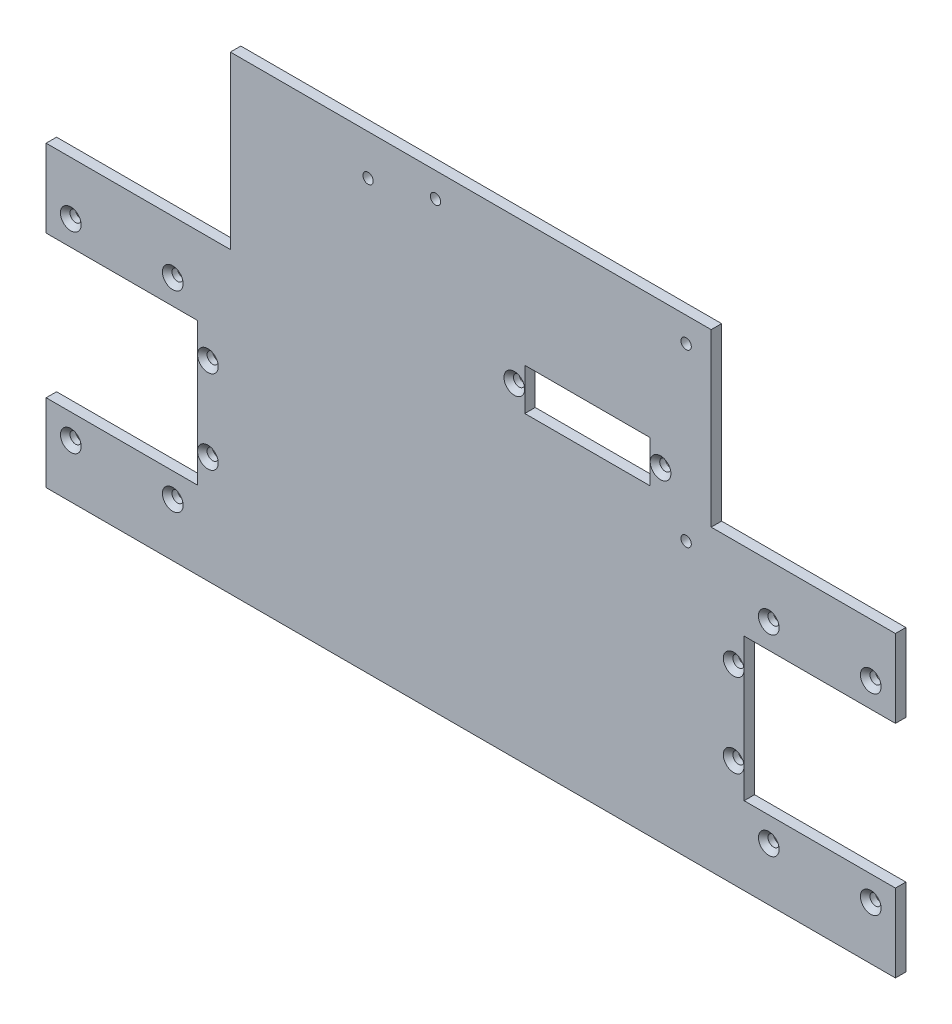
from build123d import *

# Parameters (mm, degrees)
PROFILE_EXTRUDE_DEPTH                           = 3.175
CSK_FOR_M3_FLAT_HEAD_MACHINE_SCREW1_D           = 3.4
CSK_FOR_M3_FLAT_HEAD_MACHINE_SCREW1_CSINK_D     = 6.3
CSK_FOR_M3_FLAT_HEAD_MACHINE_SCREW1_CSINK_ANGLE = 90
FILM_FEEDER_CLEARANCE_SKETCH_W                  = 46
FILM_FEEDER_CLEARANCE_SKETCH_H                  = 43.35
FILM_FEEDER_CLEARANCE_CUT_DEPTH                 = 4.175
GANTRY_MOUNTING_HOLE_SKETCH_R                   = 1.575
GANTRY_MOUNTING_HOLE_CUT_DEPTH                  = 4.175
ERASER_MOUNTING_HOLE_SKETCH_R                   = 1.575
ERASER_MOUNTING_HOLE_CUT_DEPTH                  = 4.175
FILM_FRICTION_GUIDE_MOUNTING_HOLES_D            = 3.4
FILM_FRICTION_GUIDE_MOUNTING_HOLES_CSINK_D      = 6.3
FILM_FRICTION_GUIDE_MOUNTING_HOLES_CSINK_ANGLE  = 90
BELT_PASSAGEWAY_SKETCH_W                        = 38.1
BELT_PASSAGEWAY_SKETCH_H                        = 12.7
BELT_PASSAGEWAY_CUT_DEPTH                       = 4.175
CSK_FOR_M3_FLAT_HEAD_MACHINE_SCREW3_D           = 3.4
CSK_FOR_M3_FLAT_HEAD_MACHINE_SCREW3_CSINK_D     = 6.3
CSK_FOR_M3_FLAT_HEAD_MACHINE_SCREW3_CSINK_ANGLE = 90


with BuildPart() as part:
    # Profile Sketch → Profile Extrude (new body)
    with BuildSketch(Plane.XY):
        Polygon((73.090000006, 45.35), (129.1, 45.35), (129.1, -45.35), (-129.1, -45.35), (-129.1, 45.35), (-73.090000006, 45.35), (-73.090000006, 97.350000154), (73.090000006, 97.350000154), align=None)
    extrude(amount=PROFILE_EXTRUDE_DEPTH)

    # CSK for M3 Flat Head Machine Screw1 (through all)
    with Locations(Plane(origin=(-121.6, 29.175, 3.175), x_dir=(1, 0, 0), z_dir=(0, 0, 1))):
        with Locations((0, 0), (31, 0), (31, -58.35), (0, -58.35), (212.2, 0), (243.2, 0), (243.2, -58.35), (212.2, -58.35)):
            CounterSinkHole(CSK_FOR_M3_FLAT_HEAD_MACHINE_SCREW1_D / 2, CSK_FOR_M3_FLAT_HEAD_MACHINE_SCREW1_CSINK_D / 2, counter_sink_angle=CSK_FOR_M3_FLAT_HEAD_MACHINE_SCREW1_CSINK_ANGLE)

    # Film Feeder Clearance Sketch → Film Feeder Clearance Cut (cut, through all)
    with BuildSketch(Plane.XY.offset(3.175)):
        with Locations((-106.1, 0)):
            Rectangle(FILM_FEEDER_CLEARANCE_SKETCH_W, FILM_FEEDER_CLEARANCE_SKETCH_H)
        with Locations((106.1, 0)):
            Rectangle(FILM_FEEDER_CLEARANCE_SKETCH_W, FILM_FEEDER_CLEARANCE_SKETCH_H)
    extrude(amount=-FILM_FEEDER_CLEARANCE_CUT_DEPTH, mode=Mode.SUBTRACT)

    # Gantry Mounting Hole Sketch → Gantry Mounting Hole Cut (cut, through all)
    with BuildSketch(Plane.XY.offset(3.175)):
        with Locations((-10.729999994, 89.850000154)):
            Circle(GANTRY_MOUNTING_HOLE_SKETCH_R)
        with Locations((65.470000006, 89.850000154)):
            Circle(GANTRY_MOUNTING_HOLE_SKETCH_R)
        with Locations((65.470000006, 37.850000254)):
            Circle(GANTRY_MOUNTING_HOLE_SKETCH_R)
    extrude(amount=-GANTRY_MOUNTING_HOLE_CUT_DEPTH, mode=Mode.SUBTRACT)

    # Eraser Mounting Hole Sketch → Eraser Mounting Hole Cut (cut, through all)
    with BuildSketch(Plane.XY.offset(3.175)):
        with Locations((-31.230000142, 85.0500001)):
            Circle(ERASER_MOUNTING_HOLE_SKETCH_R)
    extrude(amount=-ERASER_MOUNTING_HOLE_CUT_DEPTH, mode=Mode.SUBTRACT)

    # Film Friction Guide Mounting Holes (through all)
    with Locations(Plane(origin=(-79.925, 12.7, 3.175), x_dir=(1, 0, 0), z_dir=(0, 0, 1))):
        with Locations((0, 0), (0, -25.4), (159.85, 0), (159.85, -25.4)):
            CounterSinkHole(FILM_FRICTION_GUIDE_MOUNTING_HOLES_D / 2, FILM_FRICTION_GUIDE_MOUNTING_HOLES_CSINK_D / 2, counter_sink_angle=FILM_FRICTION_GUIDE_MOUNTING_HOLES_CSINK_ANGLE)

    # Belt Passageway Sketch → Belt Passageway Cut (cut, through all)
    with BuildSketch(Plane.XY.offset(3.175)):
        with Locations((35.470060006, 53.2875)):
            Rectangle(BELT_PASSAGEWAY_SKETCH_W, BELT_PASSAGEWAY_SKETCH_H)
    extrude(amount=-BELT_PASSAGEWAY_CUT_DEPTH, mode=Mode.SUBTRACT)

    # CSK for M3 Flat Head Machine Screw3 (through all)
    with Locations(Plane(origin=(13.245060006, 53.2875, 3.175), x_dir=(1, 0, 0), z_dir=(0, 0, 1))):
        with Locations((0, 0), (44.45, 0)):
            CounterSinkHole(CSK_FOR_M3_FLAT_HEAD_MACHINE_SCREW3_D / 2, CSK_FOR_M3_FLAT_HEAD_MACHINE_SCREW3_CSINK_D / 2, counter_sink_angle=CSK_FOR_M3_FLAT_HEAD_MACHINE_SCREW3_CSINK_ANGLE)


solid = part.part
